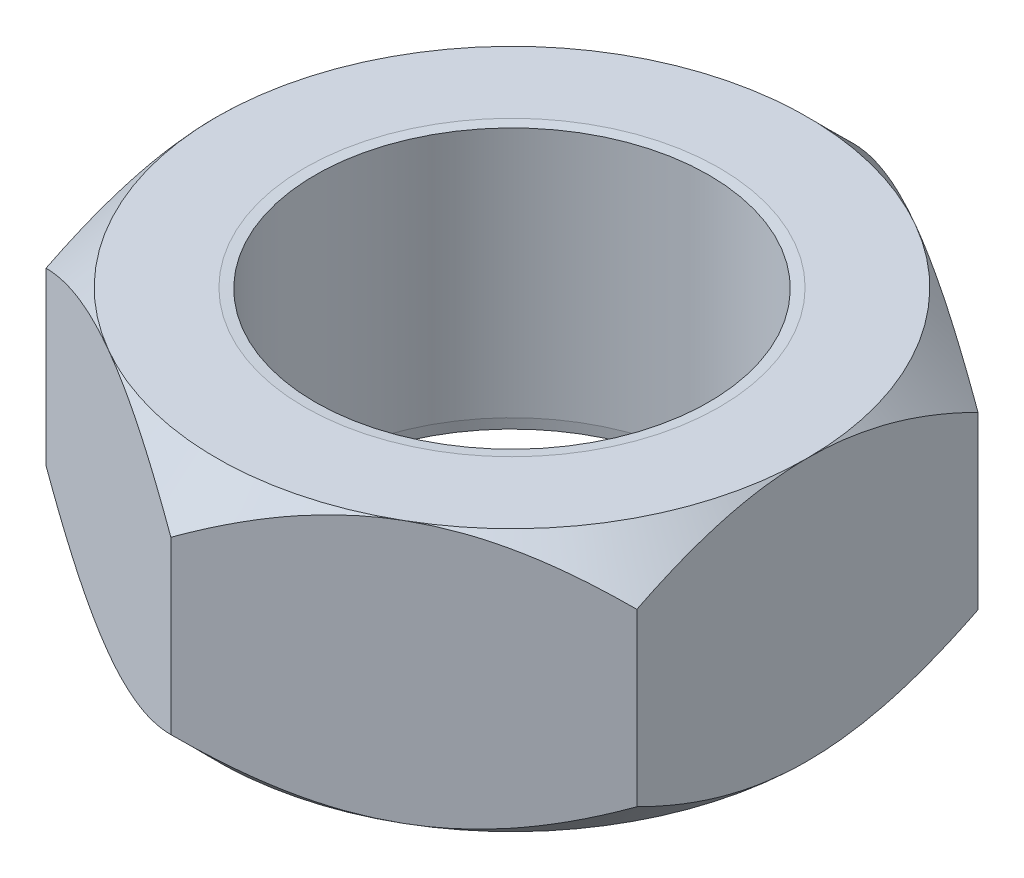
from build123d import *

# Parameters (mm, degrees)
BOSS_EXTRUDE1_DEPTH = 6.35
SKETCH2_R           = 4.7625
CUT_EXTRUDE1_DEPTH  = 7.35
CHAMFER2_SIZE       = 0.254
CHAMFER2_SIZE2      = 0.022222121
CHAMFER3_SIZE       = 0.254
CHAMFER3_SIZE2      = 0.022222121
SKETCH3_OUTSIDE_W   = 33.55
SKETCH3_OUTSIDE_H   = 35.762
SKETCH3_OUTSIDE_R   = 7.150103868
CUT_EXTRUDE2_DEPTH  = 6.35
CUT_EXTRUDE2_TAPER  = 45
SKETCH4_OUTSIDE_W   = 33.55
SKETCH4_OUTSIDE_H   = 35.762
SKETCH4_OUTSIDE_R   = 7.1501
CUT_EXTRUDE3_DEPTH  = 6.35
CUT_EXTRUDE3_TAPER  = 45


with BuildPart() as part:
    # Sketch1 → Boss-Extrude1 (new body)
    with BuildSketch(Plane(origin=(0, 0, 0), x_dir=(1, 0, 0), z_dir=(0, 1, 0))):
        Polygon((0, 8.256224319), (-7.1501, 4.12811216), (-7.1501, -4.12811216), (0, -8.256224319), (7.1501, -4.12811216), (7.1501, 4.12811216), align=None)
    extrude(amount=BOSS_EXTRUDE1_DEPTH)

    # Sketch2 → Cut-Extrude1 (cut, through all)
    with BuildSketch(Plane(origin=(0, 6.35, 0), x_dir=(1, 0, 0), z_dir=(0, 1, 0))):
        Circle(SKETCH2_R)
    extrude(amount=-CUT_EXTRUDE1_DEPTH, mode=Mode.SUBTRACT)

    # Chamfer2
    chamfer2_edges = [part.edges().sort_by_distance(p)[0] for p in [
        (-4.7625, 6.35, 0),
    ]]
    chamfer2_side = [part.faces().sort_by_distance(p)[0] for p in [
        (-3.465830418, 6.35, -6.002994375),
    ]]
    chamfer(chamfer2_edges, length=CHAMFER2_SIZE, length2=CHAMFER2_SIZE2, reference=chamfer2_side[0])

    # Chamfer3
    chamfer3_edges = [part.edges().sort_by_distance(p)[0] for p in [
        (-4.7625, 0, 0),
    ]]
    chamfer3_side = [part.faces().sort_by_distance(p)[0] for p in [
        (-4.7625, 3.16388894, 0),
    ]]
    chamfer(chamfer3_edges, length=CHAMFER3_SIZE, length2=CHAMFER3_SIZE2, reference=chamfer3_side[0])

    # Sketch3 outside → Cut-Extrude2 (cut)
    with BuildSketch(Plane(origin=(0, 6.35, 0), x_dir=(1, 0, 0), z_dir=(0, 1, 0))):
        Rectangle(SKETCH3_OUTSIDE_W, SKETCH3_OUTSIDE_H)
        Circle(SKETCH3_OUTSIDE_R, mode=Mode.SUBTRACT)
    extrude(amount=-CUT_EXTRUDE2_DEPTH, taper=CUT_EXTRUDE2_TAPER, mode=Mode.SUBTRACT)

    # Sketch4 outside → Cut-Extrude3 (cut)
    with BuildSketch(Plane.XZ):
        Rectangle(SKETCH4_OUTSIDE_W, SKETCH4_OUTSIDE_H)
        Circle(SKETCH4_OUTSIDE_R, mode=Mode.SUBTRACT)
    extrude(amount=-CUT_EXTRUDE3_DEPTH, taper=CUT_EXTRUDE3_TAPER, mode=Mode.SUBTRACT)


solid = part.part
